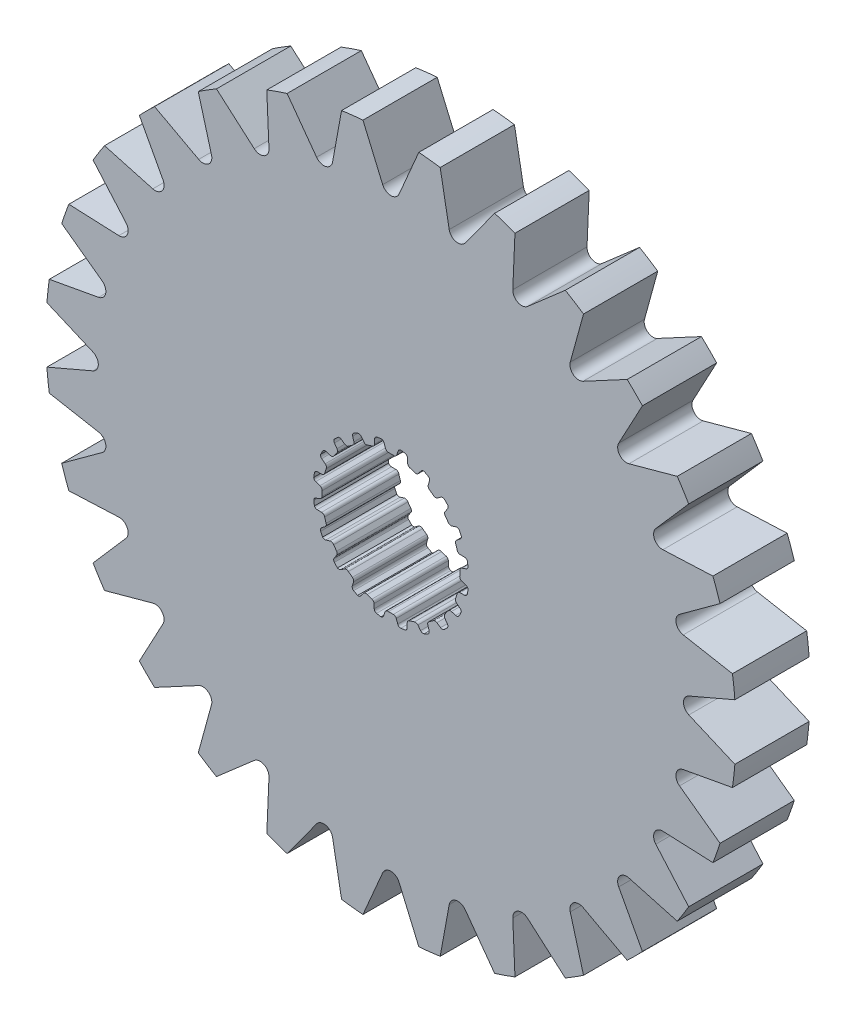
from build123d import *

# Parameters (mm, degrees)
SKETCH1_R           = 14.877001171
BOSS_EXTRUDE1_DEPTH = 1.6002
CUT_EXTRUDE1_DEPTH  = 3.2004


with BuildPart() as part:
    # Sketch1 → Boss-Extrude1 (new body, symmetric)
    with BuildSketch(Plane.XY):
        Circle(SKETCH1_R)
        with BuildLine():
            Line((-0.106949245, 2.969874934), (0.106949245, 2.969874934))
            ThreePointArc((0.106949245, 2.969874934), (0.196343213, 2.986924176), (0.253739238, 3.057547504))
            Line((0.253739238, 3.057547504), (0.315888147, 3.237526941))
            ThreePointArc((0.315888147, 3.237526941), (0.359032156, 3.298322911), (0.4281449, 3.326269005))
            Line((0.4281449, 3.326269005), (0.620027588, 3.2937547))
            ThreePointArc((0.620027588, 3.2937547), (0.689621142, 3.24802576), (0.718272212, 3.169836791))
            Line((0.718272212, 3.169836791), (0.724389167, 2.979527391))
            ThreePointArc((0.724389167, 2.979527391), (0.750934762, 2.9040661), (0.816027049, 2.857568043))
            Line((0.816027049, 2.857568043), (1.019456602, 2.791469774))
            ThreePointArc((1.019456602, 2.791469774), (1.109743823, 2.780060312), (1.186154496, 2.829490741))
            Line((1.186154496, 2.829490741), (1.300878326, 2.981456288))
            ThreePointArc((1.300878326, 2.981456288), (1.360697704, 3.02594446), (1.435063648, 3.031165762))
            Line((1.435063648, 3.031165762), (1.607507455, 2.940947809))
            ThreePointArc((1.607507455, 2.940947809), (1.659563839, 2.875951412), (1.662650905, 2.792735615))
            Line((1.662650905, 2.792735615), (1.609659636, 2.609850378))
            ThreePointArc((1.609659636, 2.609850378), (1.611587176, 2.529879385), (1.659124931, 2.465542482))
            Line((1.659124931, 2.465542482), (1.832172444, 2.339816104))
            ThreePointArc((1.832172444, 2.339816104), (1.914514976, 2.301064775), (2.002460687, 2.32446371))
            Line((2.002460687, 2.32446371), (2.158529469, 2.433539921))
            ThreePointArc((2.158529469, 2.433539921), (2.229168681, 2.457365482), (2.301508367, 2.439350895))
            Line((2.301508367, 2.439350895), (2.437633293, 2.300260456))
            ThreePointArc((2.437633293, 2.300260456), (2.467056864, 2.222358901), (2.444277744, 2.14226202))
            Line((2.444277744, 2.14226202), (2.337365406, 1.984703026))
            ThreePointArc((2.337365406, 1.984703026), (2.314486209, 1.908050449), (2.339816104, 1.832172444))
            Line((2.339816104, 1.832172444), (2.465542482, 1.659124931))
            ThreePointArc((2.465542482, 1.659124931), (2.531880064, 1.596824985), (2.622752074, 1.591901975))
            Line((2.622752074, 1.591901975), (2.804888709, 1.64741171))
            ThreePointArc((2.804888709, 1.64741171), (2.879433095, 1.648242449), (2.942665411, 1.608755366))
            Line((2.942665411, 1.608755366), (3.0291466, 1.434407582))
            ThreePointArc((3.0291466, 1.434407582), (3.033057175, 1.351226417), (2.986641646, 1.282088892))
            Line((2.986641646, 1.282088892), (2.836273564, 1.165279113))
            ThreePointArc((2.836273564, 1.165279113), (2.790827206, 1.099448241), (2.791469774, 1.019456602))
            Line((2.791469774, 1.019456602), (2.857568043, 0.816027049))
            ThreePointArc((2.857568043, 0.816027049), (2.901407091, 0.736276839), (2.986310214, 0.703513784))
            Line((2.986310214, 0.703513784), (3.1766859, 0.700023363))
            ThreePointArc((3.1766859, 0.700023363), (3.247838536, 0.677777961), (3.295773863, 0.620683653))
            Line((3.295773863, 0.620683653), (3.324145932, 0.4281449))
            ThreePointArc((3.324145932, 0.4281449), (3.302160717, 0.347826477), (3.236652255, 0.29641597))
            Line((3.236652255, 0.29641597), (3.057547504, 0.231789562))
            ThreePointArc((3.057547504, 0.231789562), (2.993982591, 0.183224379), (2.969874934, 0.106949245))
            Line((2.969874934, 0.106949245), (2.969874934, -0.106949245))
            ThreePointArc((2.969874934, -0.106949245), (2.986924176, -0.196343213), (3.057547504, -0.253739238))
            Line((3.057547504, -0.253739238), (3.237526941, -0.315888147))
            ThreePointArc((3.237526941, -0.315888147), (3.298322911, -0.359032156), (3.326269005, -0.4281449))
            Line((3.326269005, -0.4281449), (3.2937547, -0.620027588))
            ThreePointArc((3.2937547, -0.620027588), (3.24802576, -0.689621142), (3.169836791, -0.718272212))
            Line((3.169836791, -0.718272212), (2.979527391, -0.724389167))
            ThreePointArc((2.979527391, -0.724389167), (2.9040661, -0.750934762), (2.857568043, -0.816027049))
            Line((2.857568043, -0.816027049), (2.791469774, -1.019456602))
            ThreePointArc((2.791469774, -1.019456602), (2.780060312, -1.109743823), (2.829490741, -1.186154496))
            Line((2.829490741, -1.186154496), (2.981456288, -1.300878326))
            ThreePointArc((2.981456288, -1.300878326), (3.02594446, -1.360697704), (3.031165762, -1.435063648))
            Line((3.031165762, -1.435063648), (2.940947809, -1.607507455))
            ThreePointArc((2.940947809, -1.607507455), (2.875951412, -1.659563839), (2.792735615, -1.662650905))
            Line((2.792735615, -1.662650905), (2.609850378, -1.609659636))
            ThreePointArc((2.609850378, -1.609659636), (2.529879385, -1.611587176), (2.465542482, -1.659124931))
            Line((2.465542482, -1.659124931), (2.339816104, -1.832172444))
            ThreePointArc((2.339816104, -1.832172444), (2.301064775, -1.914514976), (2.32446371, -2.002460687))
            Line((2.32446371, -2.002460687), (2.433539921, -2.158529469))
            ThreePointArc((2.433539921, -2.158529469), (2.457365482, -2.229168681), (2.439350895, -2.301508367))
            Line((2.439350895, -2.301508367), (2.300260456, -2.437633293))
            ThreePointArc((2.300260456, -2.437633293), (2.222358901, -2.467056864), (2.14226202, -2.444277744))
            Line((2.14226202, -2.444277744), (1.984703026, -2.337365406))
            ThreePointArc((1.984703026, -2.337365406), (1.908050449, -2.314486209), (1.832172444, -2.339816104))
            Line((1.832172444, -2.339816104), (1.659124931, -2.465542482))
            ThreePointArc((1.659124931, -2.465542482), (1.596824985, -2.531880064), (1.591901975, -2.622752074))
            Line((1.591901975, -2.622752074), (1.64741171, -2.804888709))
            ThreePointArc((1.64741171, -2.804888709), (1.648242449, -2.879433095), (1.608755366, -2.942665411))
            Line((1.608755366, -2.942665411), (1.434407582, -3.0291466))
            ThreePointArc((1.434407582, -3.0291466), (1.351226417, -3.033057175), (1.282088892, -2.986641646))
            Line((1.282088892, -2.986641646), (1.165279113, -2.836273564))
            ThreePointArc((1.165279113, -2.836273564), (1.099448241, -2.790827206), (1.019456602, -2.791469774))
            Line((1.019456602, -2.791469774), (0.816027049, -2.857568043))
            ThreePointArc((0.816027049, -2.857568043), (0.736276839, -2.901407091), (0.703513784, -2.986310214))
            Line((0.703513784, -2.986310214), (0.700023363, -3.1766859))
            ThreePointArc((0.700023363, -3.1766859), (0.677777961, -3.247838536), (0.620683653, -3.295773863))
            Line((0.620683653, -3.295773863), (0.4281449, -3.324145932))
            ThreePointArc((0.4281449, -3.324145932), (0.347826477, -3.302160717), (0.29641597, -3.236652255))
            Line((0.29641597, -3.236652255), (0.231789562, -3.057547504))
            ThreePointArc((0.231789562, -3.057547504), (0.183224379, -2.993982591), (0.106949245, -2.969874934))
            Line((0.106949245, -2.969874934), (-0.106949245, -2.969874934))
            ThreePointArc((-0.106949245, -2.969874934), (-0.196343213, -2.986924176), (-0.253739238, -3.057547504))
            Line((-0.253739238, -3.057547504), (-0.315888147, -3.237526941))
            ThreePointArc((-0.315888147, -3.237526941), (-0.359032156, -3.298322911), (-0.4281449, -3.326269005))
            Line((-0.4281449, -3.326269005), (-0.620027588, -3.2937547))
            ThreePointArc((-0.620027588, -3.2937547), (-0.689621142, -3.24802576), (-0.718272212, -3.169836791))
            Line((-0.718272212, -3.169836791), (-0.724389167, -2.979527391))
            ThreePointArc((-0.724389167, -2.979527391), (-0.750934762, -2.9040661), (-0.816027049, -2.857568043))
            Line((-0.816027049, -2.857568043), (-1.019456602, -2.791469774))
            ThreePointArc((-1.019456602, -2.791469774), (-1.109743823, -2.780060312), (-1.186154496, -2.829490741))
            Line((-1.186154496, -2.829490741), (-1.300878326, -2.981456288))
            ThreePointArc((-1.300878326, -2.981456288), (-1.360697704, -3.02594446), (-1.435063648, -3.031165762))
            Line((-1.435063648, -3.031165762), (-1.607507455, -2.940947809))
            ThreePointArc((-1.607507455, -2.940947809), (-1.659563839, -2.875951412), (-1.662650905, -2.792735615))
            Line((-1.662650905, -2.792735615), (-1.609659636, -2.609850378))
            ThreePointArc((-1.609659636, -2.609850378), (-1.611587176, -2.529879385), (-1.659124931, -2.465542482))
            Line((-1.659124931, -2.465542482), (-1.832172444, -2.339816104))
            ThreePointArc((-1.832172444, -2.339816104), (-1.914514976, -2.301064775), (-2.002460687, -2.32446371))
            Line((-2.002460687, -2.32446371), (-2.158529469, -2.433539921))
            ThreePointArc((-2.158529469, -2.433539921), (-2.229168681, -2.457365482), (-2.301508367, -2.439350895))
            Line((-2.301508367, -2.439350895), (-2.437633293, -2.300260456))
            ThreePointArc((-2.437633293, -2.300260456), (-2.467056864, -2.222358901), (-2.444277744, -2.14226202))
            Line((-2.444277744, -2.14226202), (-2.337365406, -1.984703026))
            ThreePointArc((-2.337365406, -1.984703026), (-2.314486209, -1.908050449), (-2.339816104, -1.832172444))
            Line((-2.339816104, -1.832172444), (-2.465542482, -1.659124931))
            ThreePointArc((-2.465542482, -1.659124931), (-2.531880064, -1.596824985), (-2.622752074, -1.591901975))
            Line((-2.622752074, -1.591901975), (-2.804888709, -1.64741171))
            ThreePointArc((-2.804888709, -1.64741171), (-2.879433095, -1.648242449), (-2.942665411, -1.608755366))
            Line((-2.942665411, -1.608755366), (-3.0291466, -1.434407582))
            ThreePointArc((-3.0291466, -1.434407582), (-3.033057175, -1.351226417), (-2.986641646, -1.282088892))
            Line((-2.986641646, -1.282088892), (-2.836273564, -1.165279113))
            ThreePointArc((-2.836273564, -1.165279113), (-2.790827206, -1.099448241), (-2.791469774, -1.019456602))
            Line((-2.791469774, -1.019456602), (-2.857568043, -0.816027049))
            ThreePointArc((-2.857568043, -0.816027049), (-2.901407091, -0.736276839), (-2.986310214, -0.703513784))
            Line((-2.986310214, -0.703513784), (-3.1766859, -0.700023363))
            ThreePointArc((-3.1766859, -0.700023363), (-3.247838536, -0.677777961), (-3.295773863, -0.620683653))
            Line((-3.295773863, -0.620683653), (-3.324145932, -0.4281449))
            ThreePointArc((-3.324145932, -0.4281449), (-3.302160717, -0.347826477), (-3.236652255, -0.29641597))
            Line((-3.236652255, -0.29641597), (-3.057547504, -0.231789562))
            ThreePointArc((-3.057547504, -0.231789562), (-2.993982591, -0.183224379), (-2.969874934, -0.106949245))
            Line((-2.969874934, -0.106949245), (-2.969874934, 0.106949245))
            ThreePointArc((-2.969874934, 0.106949245), (-2.986924176, 0.196343213), (-3.057547504, 0.253739238))
            Line((-3.057547504, 0.253739238), (-3.237526941, 0.315888147))
            ThreePointArc((-3.237526941, 0.315888147), (-3.298322911, 0.359032156), (-3.326269005, 0.4281449))
            Line((-3.326269005, 0.4281449), (-3.2937547, 0.620027588))
            ThreePointArc((-3.2937547, 0.620027588), (-3.24802576, 0.689621142), (-3.169836791, 0.718272212))
            Line((-3.169836791, 0.718272212), (-2.979527391, 0.724389167))
            ThreePointArc((-2.979527391, 0.724389167), (-2.9040661, 0.750934762), (-2.857568043, 0.816027049))
            Line((-2.857568043, 0.816027049), (-2.791469774, 1.019456602))
            ThreePointArc((-2.791469774, 1.019456602), (-2.780060312, 1.109743823), (-2.829490741, 1.186154496))
            Line((-2.829490741, 1.186154496), (-2.981456288, 1.300878326))
            ThreePointArc((-2.981456288, 1.300878326), (-3.02594446, 1.360697704), (-3.031165762, 1.435063648))
            Line((-3.031165762, 1.435063648), (-2.940947809, 1.607507455))
            ThreePointArc((-2.940947809, 1.607507455), (-2.875951412, 1.659563839), (-2.792735615, 1.662650905))
            Line((-2.792735615, 1.662650905), (-2.609850378, 1.609659636))
            ThreePointArc((-2.609850378, 1.609659636), (-2.529879385, 1.611587176), (-2.465542482, 1.659124931))
            Line((-2.465542482, 1.659124931), (-2.339816104, 1.832172444))
            ThreePointArc((-2.339816104, 1.832172444), (-2.301064775, 1.914514976), (-2.32446371, 2.002460687))
            Line((-2.32446371, 2.002460687), (-2.433539921, 2.158529469))
            ThreePointArc((-2.433539921, 2.158529469), (-2.457365482, 2.229168681), (-2.439350895, 2.301508367))
            Line((-2.439350895, 2.301508367), (-2.300260456, 2.437633293))
            ThreePointArc((-2.300260456, 2.437633293), (-2.222358901, 2.467056864), (-2.14226202, 2.444277744))
            Line((-2.14226202, 2.444277744), (-1.984703026, 2.337365406))
            ThreePointArc((-1.984703026, 2.337365406), (-1.908050449, 2.314486209), (-1.832172444, 2.339816104))
            Line((-1.832172444, 2.339816104), (-1.659124931, 2.465542482))
            ThreePointArc((-1.659124931, 2.465542482), (-1.596824985, 2.531880064), (-1.591901975, 2.622752074))
            Line((-1.591901975, 2.622752074), (-1.64741171, 2.804888709))
            ThreePointArc((-1.64741171, 2.804888709), (-1.648242449, 2.879433095), (-1.608755366, 2.942665411))
            Line((-1.608755366, 2.942665411), (-1.434407582, 3.0291466))
            ThreePointArc((-1.434407582, 3.0291466), (-1.351226417, 3.033057175), (-1.282088892, 2.986641646))
            Line((-1.282088892, 2.986641646), (-1.165279113, 2.836273564))
            ThreePointArc((-1.165279113, 2.836273564), (-1.099448241, 2.790827206), (-1.019456602, 2.791469774))
            Line((-1.019456602, 2.791469774), (-0.816027049, 2.857568043))
            ThreePointArc((-0.816027049, 2.857568043), (-0.736276839, 2.901407091), (-0.703513784, 2.986310214))
            Line((-0.703513784, 2.986310214), (-0.700023363, 3.1766859))
            ThreePointArc((-0.700023363, 3.1766859), (-0.677777961, 3.247838536), (-0.620683653, 3.295773863))
            Line((-0.620683653, 3.295773863), (-0.4281449, 3.324145932))
            ThreePointArc((-0.4281449, 3.324145932), (-0.347826477, 3.302160717), (-0.29641597, 3.236652255))
            Line((-0.29641597, 3.236652255), (-0.231789562, 3.057547504))
            ThreePointArc((-0.231789562, 3.057547504), (-0.183224379, 2.993982591), (-0.106949245, 2.969874934))
        make_face(mode=Mode.SUBTRACT)
    extrude(amount=BOSS_EXTRUDE1_DEPTH, both=True)

    # Sketch2 → Cut-Extrude1 (cut)
    with BuildSketch(Plane.XY.offset(1.6002)):
        with BuildLine():
            Line((-1.204013545, 14.8282), (-0.353006455, 12.844599844))
            ThreePointArc((-0.353006455, 12.844599844), (0, 12.611925006), (0.353006455, 12.844599844))
            Line((0.353006455, 12.844599844), (1.204013545, 14.8282))
            ThreePointArc((1.204013545, 14.8282), (0, 14.877001171), (-1.204013545, 14.8282))
        make_face()
        with BuildLine():
            Line((4.473411324, 14.188507849), (3.2023482, 12.444007582))
            ThreePointArc((3.2023482, 12.444007582), (2.806417331, 12.295717715), (2.514036507, 12.601110235))
            Line((2.514036507, 12.601110235), (2.125758501, 14.724344286))
            ThreePointArc((2.125758501, 14.724344286), (3.310444195, 14.504003692), (4.473411324, 14.188507849))
        make_face()
        with BuildLine():
            Line((7.518493581, 12.837344668), (5.891110834, 11.419420819))
            ThreePointArc((5.891110834, 11.419420819), (5.472109179, 11.362951795), (5.255015181, 11.725748341))
            Line((5.255015181, 11.725748341), (5.34893614, 13.882148466))
            ThreePointArc((5.34893614, 13.882148466), (6.454888895, 13.403714903), (7.518493581, 12.837344668))
        make_face()
        with BuildLine():
            Line((10.186567175, 10.842463422), (8.284468572, 9.822216613))
            ThreePointArc((8.284468572, 9.822216613), (7.863406623, 9.860400024), (7.732485451, 10.262408462))
            Line((7.732485451, 10.262408462), (8.303895785, 12.343843755))
            ThreePointArc((8.303895785, 12.343843755), (9.275658513, 11.631307881), (10.186567175, 10.842463422))
        make_face()
        with BuildLine():
            Line((12.343843755, 8.303895785), (10.262408462, 7.732485451))
            ThreePointArc((10.262408462, 7.732485451), (9.860400024, 7.863406623), (9.822216613, 8.284468572))
            Line((9.822216613, 8.284468572), (10.842463422, 10.186567175))
            ThreePointArc((10.842463422, 10.186567175), (11.631307881, 9.275658513), (12.343843755, 8.303895785))
        make_face()
        with BuildLine():
            Line((13.882148466, 5.34893614), (11.725748341, 5.255015181))
            ThreePointArc((11.725748341, 5.255015181), (11.362951795, 5.472109179), (11.419420819, 5.891110834))
            Line((11.419420819, 5.891110834), (12.837344668, 7.518493581))
            ThreePointArc((12.837344668, 7.518493581), (13.403714903, 6.454888895), (13.882148466, 5.34893614))
        make_face()
        with BuildLine():
            Line((14.724344286, 2.125758501), (12.601110235, 2.514036507))
            ThreePointArc((12.601110235, 2.514036507), (12.295717715, 2.806417331), (12.444007582, 3.2023482))
            Line((12.444007582, 3.2023482), (14.188507849, 4.473411324))
            ThreePointArc((14.188507849, 4.473411324), (14.504003692, 3.310444195), (14.724344286, 2.125758501))
        make_face()
        with BuildLine():
            Line((14.8282, -1.204013545), (12.844599844, -0.353006455))
            ThreePointArc((12.844599844, -0.353006455), (12.611925006, 0), (12.844599844, 0.353006455))
            Line((12.844599844, 0.353006455), (14.8282, 1.204013545))
            ThreePointArc((14.8282, 1.204013545), (14.877001171, 0), (14.8282, -1.204013545))
        make_face()
        with BuildLine():
            Line((14.188507849, -4.473411324), (12.444007582, -3.2023482))
            ThreePointArc((12.444007582, -3.2023482), (12.295717715, -2.806417331), (12.601110235, -2.514036507))
            Line((12.601110235, -2.514036507), (14.724344286, -2.125758501))
            ThreePointArc((14.724344286, -2.125758501), (14.504003692, -3.310444195), (14.188507849, -4.473411324))
        make_face()
        with BuildLine():
            Line((12.837344668, -7.518493581), (11.419420819, -5.891110834))
            ThreePointArc((11.419420819, -5.891110834), (11.362951795, -5.472109179), (11.725748341, -5.255015181))
            Line((11.725748341, -5.255015181), (13.882148466, -5.34893614))
            ThreePointArc((13.882148466, -5.34893614), (13.403714903, -6.454888895), (12.837344668, -7.518493581))
        make_face()
        with BuildLine():
            Line((10.842463422, -10.186567175), (9.822216613, -8.284468572))
            ThreePointArc((9.822216613, -8.284468572), (9.860400024, -7.863406623), (10.262408462, -7.732485451))
            Line((10.262408462, -7.732485451), (12.343843755, -8.303895785))
            ThreePointArc((12.343843755, -8.303895785), (11.631307881, -9.275658513), (10.842463422, -10.186567175))
        make_face()
        with BuildLine():
            Line((8.303895785, -12.343843755), (7.732485451, -10.262408462))
            ThreePointArc((7.732485451, -10.262408462), (7.863406623, -9.860400024), (8.284468572, -9.822216613))
            Line((8.284468572, -9.822216613), (10.186567175, -10.842463422))
            ThreePointArc((10.186567175, -10.842463422), (9.275658513, -11.631307881), (8.303895785, -12.343843755))
        make_face()
        with BuildLine():
            Line((5.34893614, -13.882148466), (5.255015181, -11.725748341))
            ThreePointArc((5.255015181, -11.725748341), (5.472109179, -11.362951795), (5.891110834, -11.419420819))
            Line((5.891110834, -11.419420819), (7.518493581, -12.837344668))
            ThreePointArc((7.518493581, -12.837344668), (6.454888895, -13.403714903), (5.34893614, -13.882148466))
        make_face()
        with BuildLine():
            Line((2.125758501, -14.724344286), (2.514036507, -12.601110235))
            ThreePointArc((2.514036507, -12.601110235), (2.806417331, -12.295717715), (3.2023482, -12.444007582))
            Line((3.2023482, -12.444007582), (4.473411324, -14.188507849))
            ThreePointArc((4.473411324, -14.188507849), (3.310444195, -14.504003692), (2.125758501, -14.724344286))
        make_face()
        with BuildLine():
            Line((-1.204013545, -14.8282), (-0.353006455, -12.844599844))
            ThreePointArc((-0.353006455, -12.844599844), (0, -12.611925006), (0.353006455, -12.844599844))
            Line((0.353006455, -12.844599844), (1.204013545, -14.8282))
            ThreePointArc((1.204013545, -14.8282), (0, -14.877001171), (-1.204013545, -14.8282))
        make_face()
        with BuildLine():
            Line((-4.473411324, -14.188507849), (-3.2023482, -12.444007582))
            ThreePointArc((-3.2023482, -12.444007582), (-2.806417331, -12.295717715), (-2.514036507, -12.601110235))
            Line((-2.514036507, -12.601110235), (-2.125758501, -14.724344286))
            ThreePointArc((-2.125758501, -14.724344286), (-3.310444195, -14.504003692), (-4.473411324, -14.188507849))
        make_face()
        with BuildLine():
            Line((-7.518493581, -12.837344668), (-5.891110834, -11.419420819))
            ThreePointArc((-5.891110834, -11.419420819), (-5.472109179, -11.362951795), (-5.255015181, -11.725748341))
            Line((-5.255015181, -11.725748341), (-5.34893614, -13.882148466))
            ThreePointArc((-5.34893614, -13.882148466), (-6.454888895, -13.403714903), (-7.518493581, -12.837344668))
        make_face()
        with BuildLine():
            Line((-10.186567175, -10.842463422), (-8.284468572, -9.822216613))
            ThreePointArc((-8.284468572, -9.822216613), (-7.863406623, -9.860400024), (-7.732485451, -10.262408462))
            Line((-7.732485451, -10.262408462), (-8.303895785, -12.343843755))
            ThreePointArc((-8.303895785, -12.343843755), (-9.275658513, -11.631307881), (-10.186567175, -10.842463422))
        make_face()
        with BuildLine():
            Line((-12.343843755, -8.303895785), (-10.262408462, -7.732485451))
            ThreePointArc((-10.262408462, -7.732485451), (-9.860400024, -7.863406623), (-9.822216613, -8.284468572))
            Line((-9.822216613, -8.284468572), (-10.842463422, -10.186567175))
            ThreePointArc((-10.842463422, -10.186567175), (-11.631307881, -9.275658513), (-12.343843755, -8.303895785))
        make_face()
        with BuildLine():
            Line((-13.882148466, -5.34893614), (-11.725748341, -5.255015181))
            ThreePointArc((-11.725748341, -5.255015181), (-11.362951795, -5.472109179), (-11.419420819, -5.891110834))
            Line((-11.419420819, -5.891110834), (-12.837344668, -7.518493581))
            ThreePointArc((-12.837344668, -7.518493581), (-13.403714903, -6.454888895), (-13.882148466, -5.34893614))
        make_face()
        with BuildLine():
            Line((-14.724344286, -2.125758501), (-12.601110235, -2.514036507))
            ThreePointArc((-12.601110235, -2.514036507), (-12.295717715, -2.806417331), (-12.444007582, -3.2023482))
            Line((-12.444007582, -3.2023482), (-14.188507849, -4.473411324))
            ThreePointArc((-14.188507849, -4.473411324), (-14.504003692, -3.310444195), (-14.724344286, -2.125758501))
        make_face()
        with BuildLine():
            Line((-14.8282, 1.204013545), (-12.844599844, 0.353006455))
            ThreePointArc((-12.844599844, 0.353006455), (-12.611925006, 0), (-12.844599844, -0.353006455))
            Line((-12.844599844, -0.353006455), (-14.8282, -1.204013545))
            ThreePointArc((-14.8282, -1.204013545), (-14.877001171, 0), (-14.8282, 1.204013545))
        make_face()
        with BuildLine():
            Line((-14.188507849, 4.473411324), (-12.444007582, 3.2023482))
            ThreePointArc((-12.444007582, 3.2023482), (-12.295717715, 2.806417331), (-12.601110235, 2.514036507))
            Line((-12.601110235, 2.514036507), (-14.724344286, 2.125758501))
            ThreePointArc((-14.724344286, 2.125758501), (-14.504003692, 3.310444195), (-14.188507849, 4.473411324))
        make_face()
        with BuildLine():
            Line((-12.837344668, 7.518493581), (-11.419420819, 5.891110834))
            ThreePointArc((-11.419420819, 5.891110834), (-11.362951795, 5.472109179), (-11.725748341, 5.255015181))
            Line((-11.725748341, 5.255015181), (-13.882148466, 5.34893614))
            ThreePointArc((-13.882148466, 5.34893614), (-13.403714903, 6.454888895), (-12.837344668, 7.518493581))
        make_face()
        with BuildLine():
            Line((-10.842463422, 10.186567175), (-9.822216613, 8.284468572))
            ThreePointArc((-9.822216613, 8.284468572), (-9.860400024, 7.863406623), (-10.262408462, 7.732485451))
            Line((-10.262408462, 7.732485451), (-12.343843755, 8.303895785))
            ThreePointArc((-12.343843755, 8.303895785), (-11.631307881, 9.275658513), (-10.842463422, 10.186567175))
        make_face()
        with BuildLine():
            Line((-8.303895785, 12.343843755), (-7.732485451, 10.262408462))
            ThreePointArc((-7.732485451, 10.262408462), (-7.863406623, 9.860400024), (-8.284468572, 9.822216613))
            Line((-8.284468572, 9.822216613), (-10.186567175, 10.842463422))
            ThreePointArc((-10.186567175, 10.842463422), (-9.275658513, 11.631307881), (-8.303895785, 12.343843755))
        make_face()
        with BuildLine():
            Line((-5.34893614, 13.882148466), (-5.255015181, 11.725748341))
            ThreePointArc((-5.255015181, 11.725748341), (-5.472109179, 11.362951795), (-5.891110834, 11.419420819))
            Line((-5.891110834, 11.419420819), (-7.518493581, 12.837344668))
            ThreePointArc((-7.518493581, 12.837344668), (-6.454888895, 13.403714903), (-5.34893614, 13.882148466))
        make_face()
        with BuildLine():
            Line((-2.125758501, 14.724344286), (-2.514036507, 12.601110235))
            ThreePointArc((-2.514036507, 12.601110235), (-2.806417331, 12.295717715), (-3.2023482, 12.444007582))
            Line((-3.2023482, 12.444007582), (-4.473411324, 14.188507849))
            ThreePointArc((-4.473411324, 14.188507849), (-3.310444195, 14.504003692), (-2.125758501, 14.724344286))
        make_face()
    extrude(amount=-CUT_EXTRUDE1_DEPTH, mode=Mode.SUBTRACT)


solid = part.part
